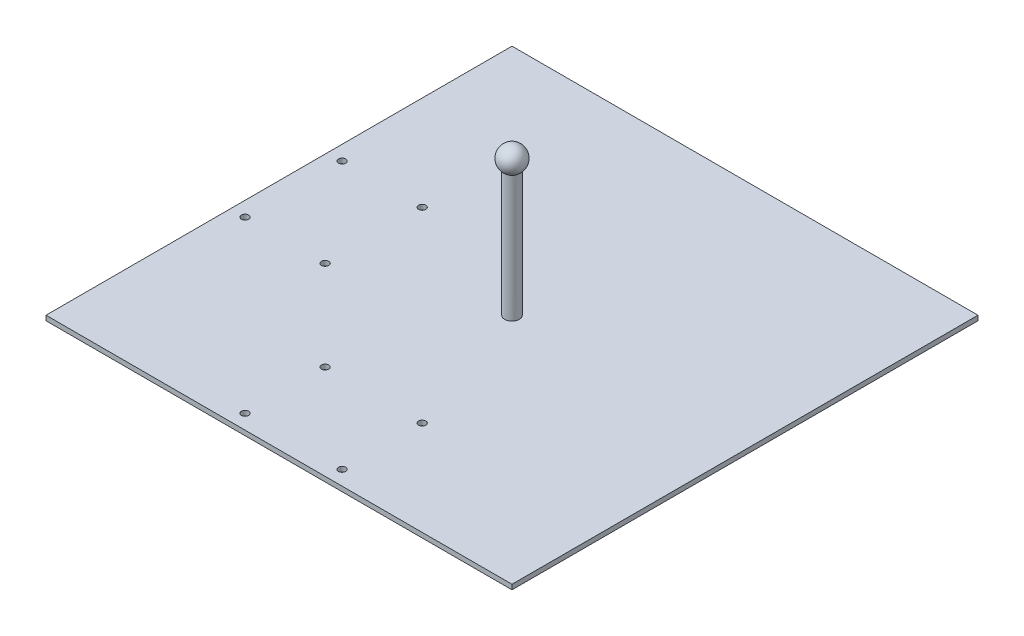
from build123d import *

# Parameters (mm, degrees)
SKETCH1_W                        = 609.6
SKETCH1_H                        = 609.6
BOSS_EXTRUDE1_DEPTH              = 6.35
F_3_8_0_375_DIAMETER_HOLE1_D     = 9.525
F_3_8_0_375_DIAMETER_HOLE1_DEPTH = 11.684
F_3_8_0_375_DIAMETER_HOLE1_TIP   = 2.861598698
SKETCH4_R                        = 9.525
BOSS_EXTRUDE2_DEPTH              = 165.1


with BuildPart() as part:
    # Sketch1 → Boss-Extrude1 (new body)
    with BuildSketch(Plane(origin=(0, 0, 0), x_dir=(1, 0, 0), z_dir=(0, 1, 0))):
        Rectangle(SKETCH1_W, SKETCH1_H)
    extrude(amount=BOSS_EXTRUDE1_DEPTH)

    # 3/8 (0.375) Diameter Hole1
    with Locations(Plane(origin=(0, 6.35, 0), x_dir=(1, 0, 0), z_dir=(0, 1, 0))):
        with Locations((-63.5, -285.75), (63.5, -285.75), (-285.75, 63.5), (-285.75, -63.5), (-63.5, -180.975), (63.5, -180.975), (-180.975, -63.5), (-180.975, 63.5)):
            Hole(F_3_8_0_375_DIAMETER_HOLE1_D / 2, depth=F_3_8_0_375_DIAMETER_HOLE1_DEPTH)
            with Locations((0, 0, -(F_3_8_0_375_DIAMETER_HOLE1_DEPTH + F_3_8_0_375_DIAMETER_HOLE1_TIP / 2))):  # 118° drill point
                Cone(0, F_3_8_0_375_DIAMETER_HOLE1_D / 2, F_3_8_0_375_DIAMETER_HOLE1_TIP, mode=Mode.SUBTRACT)

    # Sketch4 → Boss-Extrude2 (add)
    with BuildSketch(Plane(origin=(0, 6.35, 0), x_dir=(1, 0, 0), z_dir=(0, 1, 0))):
        Circle(SKETCH4_R)
    extrude(amount=BOSS_EXTRUDE2_DEPTH)

    # Sketch5 → Revolve3 (revolve)
    with BuildSketch(Plane.XY):
        with BuildLine():
            Line((0, 200.025), (0, 168.275))
            ThreePointArc((0, 168.275), (-15.875, 184.15), (0, 200.025))
        make_face()
    revolve(axis=Axis((0, 599.823656089, 0), (0, -1, 0)))


solid = part.part
